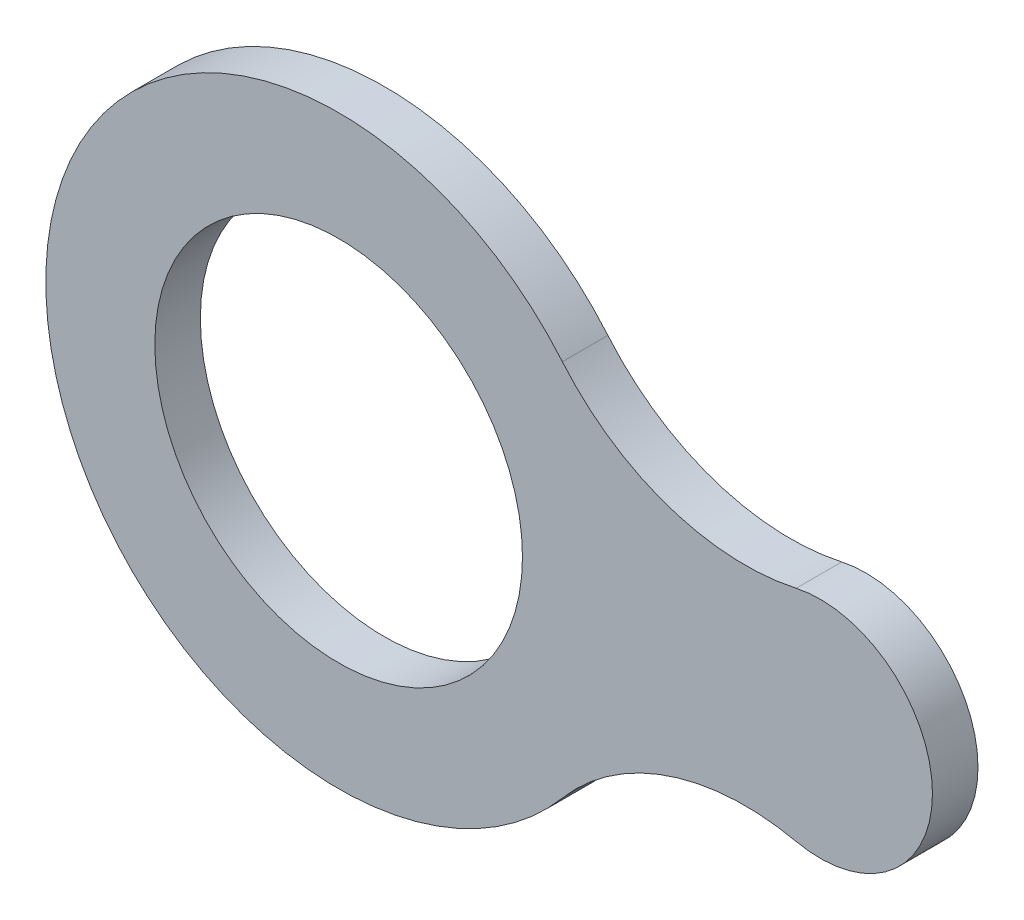
from build123d import *

# Parameters (mm, degrees)
SKETCH1_R          = 28.25
BASE_EXTRUDE_DEPTH = 7


with BuildPart() as part:
    # Sketch1 → Base-Extrude (new body)
    with BuildSketch(Plane.XY):
        with BuildLine():
            ThreePointArc((34.37992312, 29.034821961), (-45, 0), (34.37992312, -29.034821961))
            ThreePointArc((34.37992312, -29.034821961), (50.650379443, -17.946188292), (70.309608401, -16.850623426))
            ThreePointArc((70.309608401, -16.850623426), (91.25, 0), (70.309608401, 16.850623426))
            ThreePointArc((70.309608401, 16.850623426), (50.650379443, 17.946188292), (34.37992312, 29.034821961))
        make_face()
        Circle(SKETCH1_R, mode=Mode.SUBTRACT)
    extrude(amount=BASE_EXTRUDE_DEPTH)


solid = part.part
